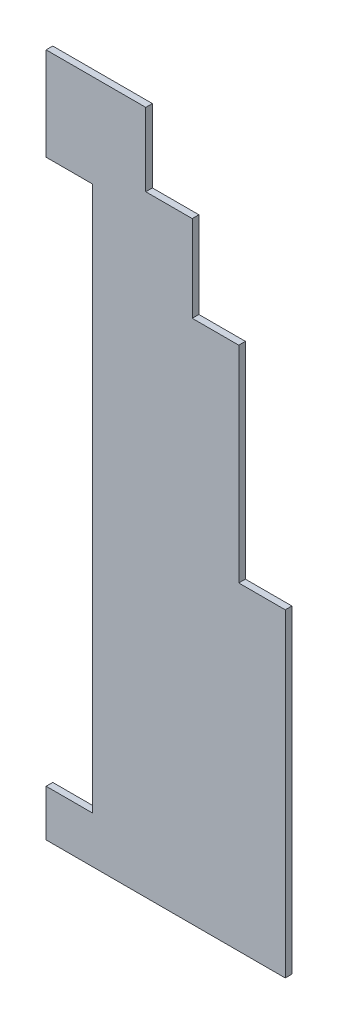
from build123d import *

# Parameters (mm, degrees)
RESSALTO_EXTRUS_O1_DEPTH = 1


with BuildPart() as part:
    # Esboço1 → Ressalto-extrusão1 (new body)
    with BuildSketch(Plane.XY):
        Polygon((0, 103), (15, 103), (15, 92), (22, 92), (22, 79), (29, 79), (29, 48), (36, 48), (36, 0), (0, 0), (0, 7), (7, 7), (7, 89), (0, 89), align=None)
    extrude(amount=RESSALTO_EXTRUS_O1_DEPTH)


solid = part.part
